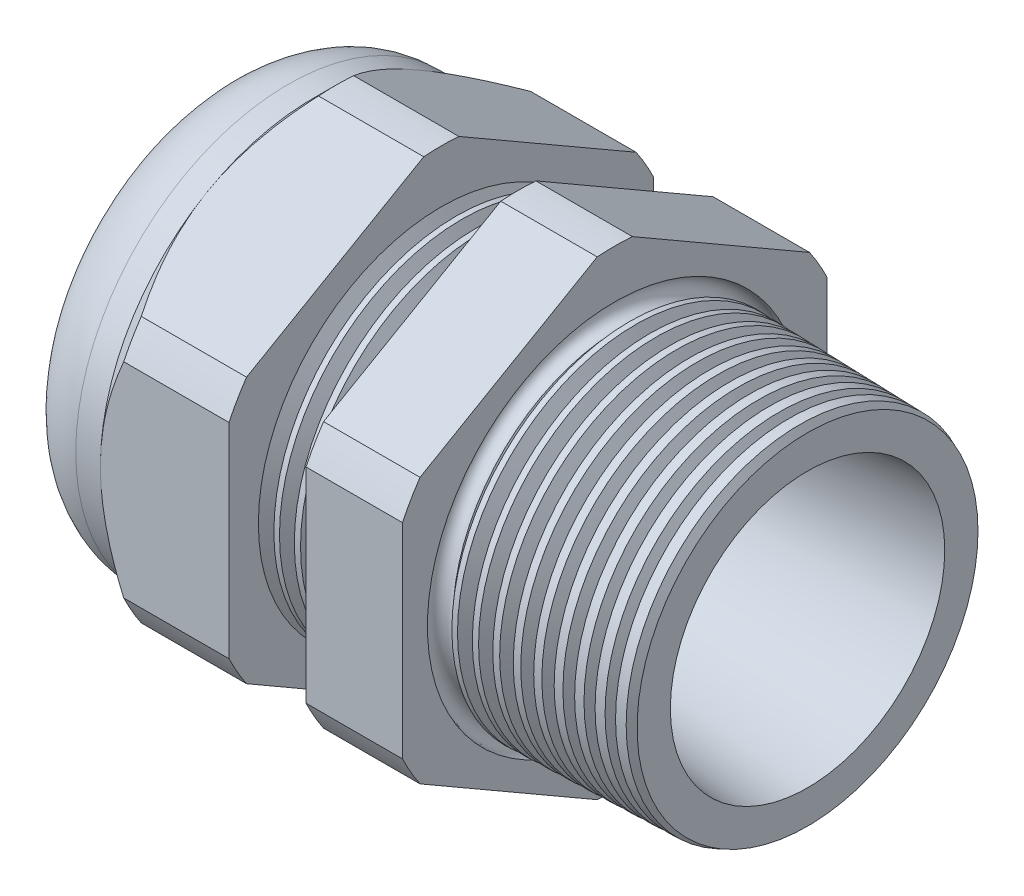
from build123d import *

# Parameters (mm, degrees)
LPATTERN6_COUNT    = 4
LPATTERN6_PITCH    = 1.5748
LPATTERN7_COUNT    = 10
LPATTERN7_PITCH    = 1.5748
SKETCH12_OUTSIDE_W = 88.86
SKETCH12_OUTSIDE_H = 88.86
CUT_EXTRUDE2_DEPTH = 39.474
FILLET4_R          = 5.588
SKETCH19_OUTSIDE_W = 56.502
SKETCH19_OUTSIDE_H = 60.134
SKETCH19_OUTSIDE_R = 16.51
CUT_EXTRUDE3_DEPTH = 3.99796
CUT_EXTRUDE3_DRAFT = -45
SKETCH28_R         = 0.8255


with BuildPart() as part:
    # Sketch10 → Revolve2 (revolve)
    with BuildSketch(Plane.XY, mode=Mode.PRIVATE) as revolve2_sk:
        Polygon((-31.362, 8.001), (-21.362, 8.001), (7.112, 10.668), (7.112, 13.478382069), (-7.874, 13.87080429), (-7.874, 33.02), (-15.374, 33.02), (-15.374, 14.067198702), (-21.362, 14.224), (-21.362, 33.02), (-31.362, 33.02), (-31.362, 16.51), (-38.862, 16.51), (-38.862, 10.668), (-31.362, 10.668), align=None)
    revolve(revolve2_sk.sketch.rotate(Axis((0, 0, 0), (-1, 0, 0)), 90), axis=Axis((0, 0, 0), (-1, 0, 0)))  # turned: the seam where the file's is

    # Sketch26 → Cut-Revolve1 (revolve, cut)
    with BuildSketch(Plane.XY, mode=Mode.PRIVATE) as cut_revolve1_sk:
        Polygon((-21.362, 14.224), (-20.189226271, 14.193289839), (-20.802208915, 13.192993077), align=None)
    cut_revolve1 = revolve(cut_revolve1_sk.sketch.rotate(Axis((0, 0, 0), (-1, 0, 0)), 90), axis=Axis((0, 0, 0), (-1, 0, 0)), mode=Mode.SUBTRACT)  # turned: the seam where the file's is

    # LPattern6: Cut-Revolve1 ×4
    with Locations(*[(i * LPATTERN6_PITCH, 0, 0) for i in range(1, LPATTERN6_COUNT)]):
        add(cut_revolve1, mode=Mode.SUBTRACT)

    # Sketch27 → Cut-Revolve2 (revolve, cut)
    with BuildSketch(Plane.XY, mode=Mode.PRIVATE) as cut_revolve2_sk:
        Polygon((-7.874, 13.87080429), (-6.701226271, 13.840094129), (-7.314208915, 12.839797367), align=None)
    cut_revolve2 = revolve(cut_revolve2_sk.sketch.rotate(Axis((0, 0, 0), (-1, 0, 0)), 90), axis=Axis((0, 0, 0), (-1, 0, 0)), mode=Mode.SUBTRACT)  # turned: the seam where the file's is

    # LPattern7: Cut-Revolve2 ×10
    with Locations(*[(i * LPATTERN7_PITCH, 0, 0) for i in range(1, LPATTERN7_COUNT)]):
        add(cut_revolve2, mode=Mode.SUBTRACT)

    # Sketch12 outside → Cut-Extrude2 (cut, through all)
    with BuildSketch(Plane.ZY.offset(31.362)):
        Rectangle(SKETCH12_OUTSIDE_W, SKETCH12_OUTSIDE_H)
        with BuildLine():
            Line((-1.366648898, 18.27507078), (-15.143351102, 10.321088053))
            ThreePointArc((-15.143351102, 10.321088053), (-15.870868152, 9.16305), (-16.51, 7.953982726))
            Line((-16.51, 7.953982726), (-16.51, -7.953982726))
            ThreePointArc((-16.51, -7.953982726), (-15.870868152, -9.16305), (-15.143351102, -10.321088053))
            Line((-15.143351102, -10.321088053), (-1.366648898, -18.27507078))
            ThreePointArc((-1.366648898, -18.27507078), (0, -18.3261), (1.366648898, -18.27507078))
            Line((1.366648898, -18.27507078), (15.143351102, -10.321088053))
            ThreePointArc((15.143351102, -10.321088053), (15.870868152, -9.16305), (16.51, -7.953982726))
            Line((16.51, -7.953982726), (16.51, 7.953982726))
            ThreePointArc((16.51, 7.953982726), (15.870868152, 9.16305), (15.143351102, 10.321088053))
            Line((15.143351102, 10.321088053), (1.366648898, 18.27507078))
            ThreePointArc((1.366648898, 18.27507078), (0, 18.3261), (-1.366648898, 18.27507078))
        make_face(mode=Mode.SUBTRACT)
    extrude(amount=-CUT_EXTRUDE2_DEPTH, mode=Mode.SUBTRACT)

    # Fillet4
    fillet4_edges = [part.edges().sort_by_distance(p)[0] for p in [
        (-38.862, 0, 16.51),
    ]]
    fillet(fillet4_edges, radius=FILLET4_R)


with BuildPart() as body_2:
    # Sketch30 → Revolve8 (revolve)
    with BuildSketch(Plane.XY, mode=Mode.PRIVATE) as revolve8_sk:
        with BuildLine():
            Line((-37.8714, 10.668), (-31.362, 10.668))
            Line((-31.362, 10.668), (-31.362, 8.001))
            Line((-31.362, 8.001), (-38.1, 8.001))
            Line((-38.1, 8.001), (-38.1, 10.4394))
            ThreePointArc((-38.1, 10.4394), (-38.03304461, 10.60104461), (-37.8714, 10.668))
        make_face()
    revolve(revolve8_sk.sketch.rotate(Axis((0, 0, 0), (-1, 0, 0)), 90), axis=Axis((0, 0, 0), (-1, 0, 0)))  # turned: the seam where the file's is


with BuildPart() as cut_extrude3_tool:
    # Sketch19 outside → Cut-Extrude3 (with draft: the straight prism first)
    with BuildSketch(Plane.ZY.offset(31.362)):
        Rectangle(SKETCH19_OUTSIDE_W, SKETCH19_OUTSIDE_H)
        Circle(SKETCH19_OUTSIDE_R, mode=Mode.SUBTRACT)
    extrude(amount=-CUT_EXTRUDE3_DEPTH)
    # Cut-Extrude3: the draft: its side faces are tilted about the plane it starts from
    cut_extrude3_sides = [cut_extrude3_tool.faces().sort_by_distance(p)[0] for p in [
        (-29.36302, -30.067, 0),
        (-29.36302, 0, 28.251),
        (-29.36302, 30.067, 0),
        (-29.36302, 0, -28.251),
        (-29.36302, 0, -16.51),
    ]]
    draft(cut_extrude3_sides, Plane.ZY.offset(31.362), CUT_EXTRUDE3_DRAFT)


with BuildPart() as part_1:
    add(part.part)

    # Cut-Extrude3: cut by cut_extrude3_tool
    add(cut_extrude3_tool.part, mode=Mode.SUBTRACT)

    # Sketch28 → Cut-Revolve3 (revolve, cut)
    with BuildSketch(Plane.XY, mode=Mode.PRIVATE) as cut_revolve3_sk:
        with Locations((-7.8486, -13.74380429)):
            Circle(SKETCH28_R)
    revolve(cut_revolve3_sk.sketch.rotate(Axis((7.112, 0, 0), (-1, 0, 0)), 90), axis=Axis((7.112, 0, 0), (-1, 0, 0)), mode=Mode.SUBTRACT)  # turned: the seam where the file's is


solid = Compound([body_2.part, part_1.part])
